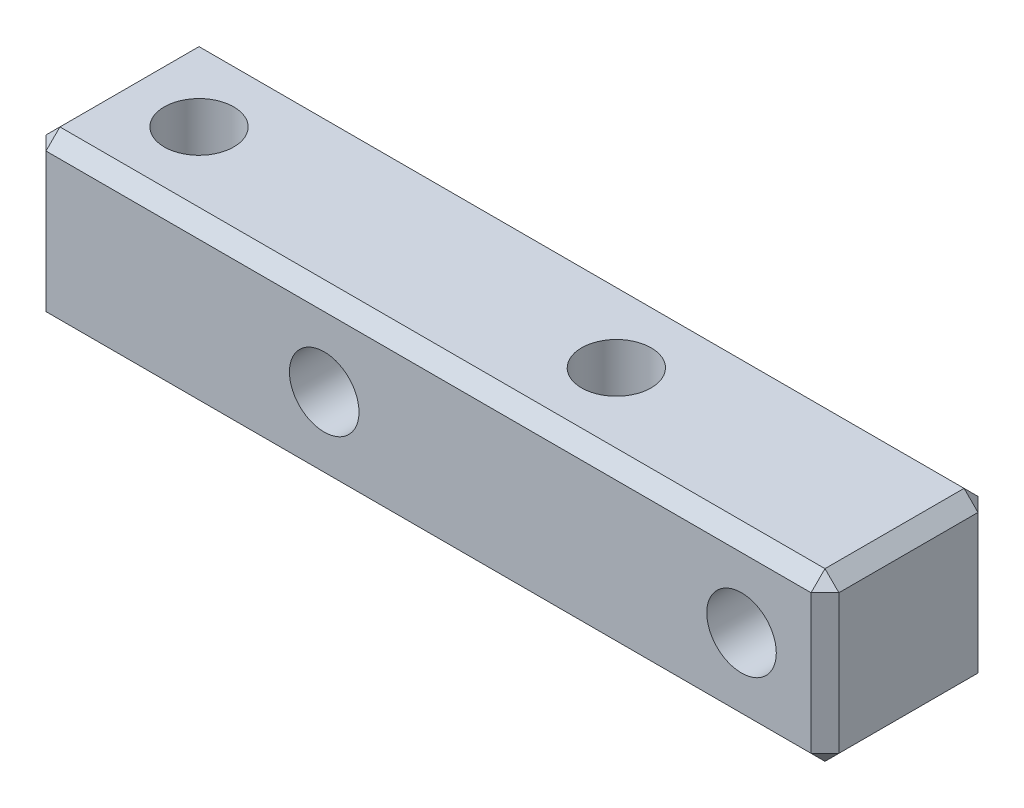
from build123d import *

# Parameters (mm, degrees)
SKETCH_2_W         = 28.5
SKETCH_2_H         = 6
SKETCH_2_R         = 0.5
EXTRUDE_1_DEPTH    = 3
HOLE_WIZARD_M3_1_D = 2.5
HOLE_WIZARD_M3_2_D = 2.5
CHAMFER_1_SIZE     = 0.5


with BuildPart() as part:
    # 草图2 → 凸台-拉伸1 (new body, symmetric)
    with BuildSketch(Plane.XY):
        with Locations((-11.25, 0)):
            Rectangle(SKETCH_2_W, SKETCH_2_H)
        with Locations((-15, 0)):
            Circle(SKETCH_2_R, mode=Mode.SUBTRACT)
        Circle(SKETCH_2_R, mode=Mode.SUBTRACT)
    extrude(amount=EXTRUDE_1_DEPTH, both=True)

    # M3 螺纹孔1 (through all)
    with Locations(Plane.XY.offset(3)):
        with Locations((0, 0), (-15, 0)):
            Hole(HOLE_WIZARD_M3_1_D / 2)

    # M3 螺纹孔2 (through all)
    with Locations(Plane(origin=(0, 3, 0), x_dir=(1, 0, 0), z_dir=(0, 1, 0))):
        with Locations((-7.5, 0), (-22.5, 0)):
            Hole(HOLE_WIZARD_M3_2_D / 2)

    # 倒角1
    chamfer_1_edges = [part.edges().sort_by_distance(p)[0] for p in [
        (-11.25, -3, 3),
        (3, 0, 3),
        (-11.25, 3, 3),
        (3, 0, -3),
        (-11.25, -3, -3),
        (-25.5, 0, -3),
        (-11.25, 3, -3),
        (-25.5, 0, 3),
        (3, 3, 0),
        (3, -3, 0),
        (-25.5, -3, 0),
        (-25.5, 3, 0),
    ]]
    chamfer(chamfer_1_edges, length=CHAMFER_1_SIZE)


solid = part.part
